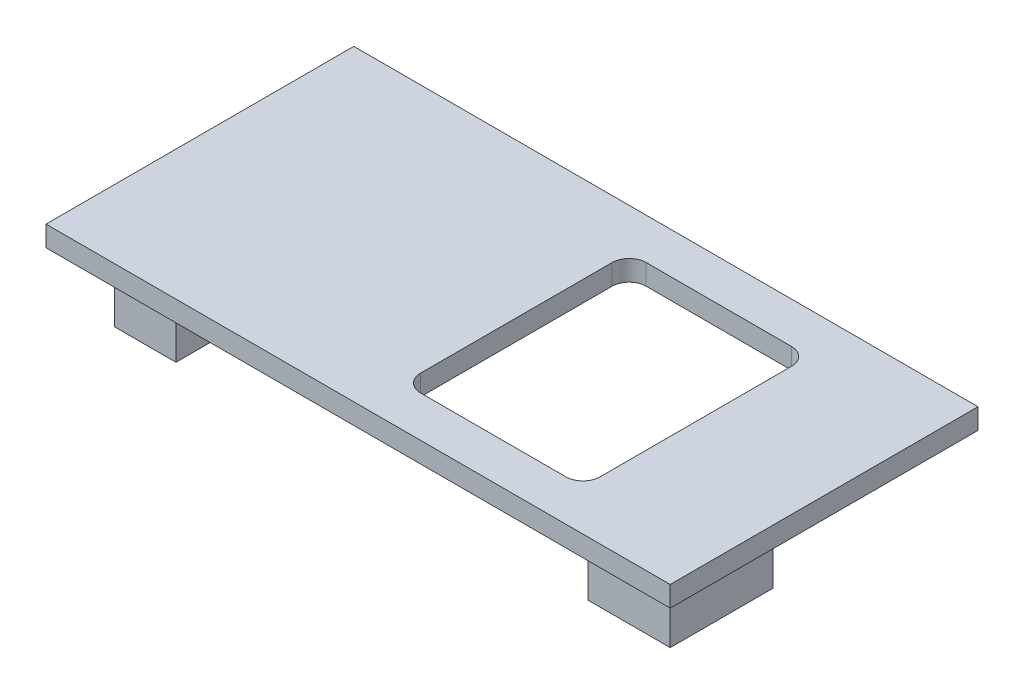
from build123d import *

# Parameters (mm, degrees)
SKETCH1_W           = 36.5
SKETCH1_H           = 18
BOSS_EXTRUDE1_DEPTH = 1.2
SKETCH2_W           = 3.6
SKETCH2_H           = 5
SKETCH2_W_2         = 4.8
SKETCH2_H_2         = 6
BOSS_EXTRUDE2_DEPTH = 4
CUT_EXTRUDE1_REACH  = 7.2
SKETCH3_W           = 10.5
SKETCH3_H           = 13.2
FILLET1_R           = 1


with BuildPart() as part:
    # Sketch1 → Boss-Extrude1 (new body)
    with BuildSketch(Plane(origin=(0, 0, 0), x_dir=(1, 0, 0), z_dir=(0, 1, 0))):
        with Locations((18.25, 9)):
            Rectangle(SKETCH1_W, SKETCH1_H)
    extrude(amount=BOSS_EXTRUDE1_DEPTH)

    # Sketch2 → Boss-Extrude2 (add)
    with BuildSketch(Plane.XZ):
        with Locations((3.8, -4.5)):
            Rectangle(SKETCH2_W, SKETCH2_H)
        with Locations((32.1, -5)):
            Rectangle(SKETCH2_W_2, SKETCH2_H_2)
    extrude(amount=BOSS_EXTRUDE2_DEPTH)

    # Sketch3 → Cut-Extrude1 (cut, up to next)
    with BuildSketch(Plane(origin=(0, 1.2, 0), x_dir=(1, 0, 0), z_dir=(0, 1, 0)), mode=Mode.PRIVATE) as cut_extrude1_sk1:
        with Locations((23.75, 9)):
            Rectangle(SKETCH3_W, SKETCH3_H)
    cut_extrude1_tool1 = extrude(cut_extrude1_sk1.sketch, amount=-CUT_EXTRUDE1_REACH, mode=Mode.PRIVATE) & part.part
    add(cut_extrude1_tool1.solids().sort_by_distance((23.75, 1.2, -9))[0], mode=Mode.SUBTRACT)

    # Fillet1
    fillet1_edges = [part.edges().sort_by_distance(p)[0] for p in [
        (18.5, 0.6, -2.4),
        (18.5, 0.6, -15.6),
        (29, 0.6, -15.6),
        (29, 0.6, -2.4),
    ]]
    fillet(fillet1_edges, radius=FILLET1_R)


solid = part.part
